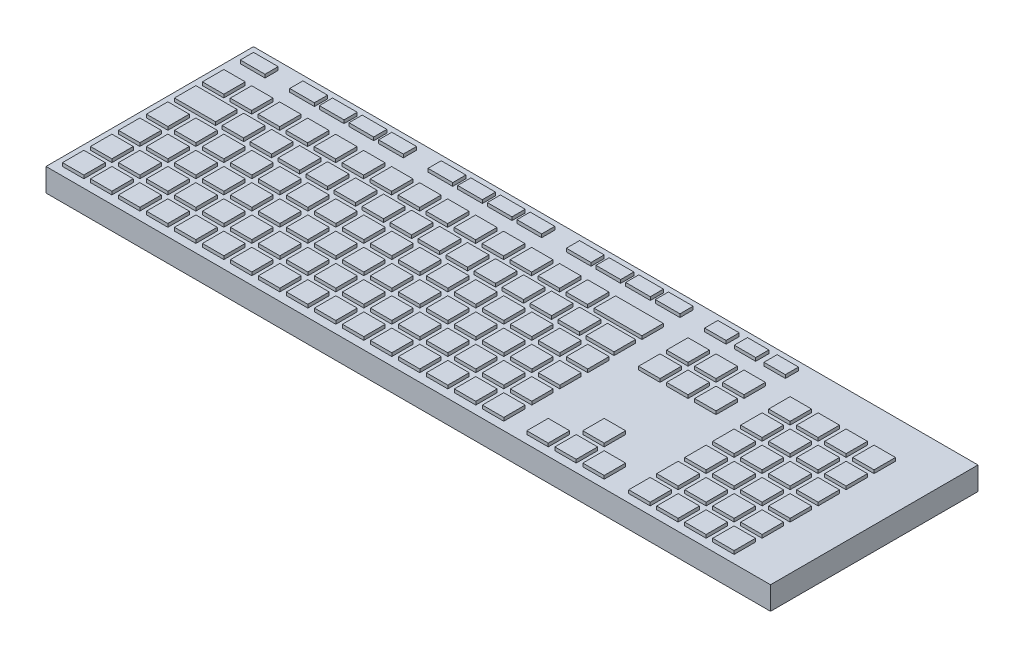
from build123d import *

# Parameters (mm, degrees)
SKETCH1_W            = 440
SKETCH1_H            = 126
BOSS_EXTRUDE1_DEPTH  = 14
SKETCH4_W            = 15
SKETCH4_H            = 8
BOSS_EXTRUDE2_DEPTH  = 2
SKETCH5_W            = 15
SKETCH5_H            = 8
BOSS_EXTRUDE3_DEPTH  = 2
LPATTERN1_COUNT      = 4
LPATTERN1_PITCH      = 18
SKETCH6_W            = 15
SKETCH6_H            = 8
BOSS_EXTRUDE4_DEPTH  = 2
LPATTERN2_COUNT      = 4
LPATTERN2_PITCH      = 18
SKETCH7_W            = 15
SKETCH7_H            = 8
BOSS_EXTRUDE5_DEPTH  = 2
LPATTERN3_COUNT      = 4
LPATTERN3_PITCH      = 18
SKETCH8_W            = 13
SKETCH8_H            = 8
BOSS_EXTRUDE6_DEPTH  = 2
LPATTERN4_COUNT      = 3
LPATTERN4_PITCH      = 18
SKETCH9_W            = 13
SKETCH9_H            = 13
BOSS_EXTRUDE7_DEPTH  = 2
SKETCH10_W           = 13
SKETCH10_H           = 13
BOSS_EXTRUDE8_DEPTH  = 2
LPATTERN5_COUNT      = 13
LPATTERN5_PITCH      = 17
SKETCH11_W           = 29
SKETCH11_H           = 13
BOSS_EXTRUDE9_DEPTH  = 2
SKETCH12_W           = 25
SKETCH12_H           = 13
BOSS_EXTRUDE10_DEPTH = 2
SKETCH13_W           = 13
SKETCH13_H           = 13
BOSS_EXTRUDE11_DEPTH = 2
LPATTERN6_COUNT      = 13
LPATTERN6_PITCH      = 17
SKETCH14_W           = 17
SKETCH14_H           = 13
BOSS_EXTRUDE12_DEPTH = 2
SKETCH15_W           = 13
SKETCH15_H           = 13
BOSS_EXTRUDE13_DEPTH = 2
LPATTERN7_COUNT      = 16
LPATTERN7_PITCH      = 17
LPATTERN7_COUNT_DIR2 = 4
LPATTERN7_PITCH_DIR2 = 17
SKETCH16_W           = 13
SKETCH16_H           = 13
BOSS_EXTRUDE14_DEPTH = 2
LPATTERN8_COUNT      = 3
LPATTERN8_PITCH      = 17
LPATTERN8_COUNT_DIR2 = 2
LPATTERN8_PITCH_DIR2 = 17
SKETCH17_W           = 13
SKETCH17_H           = 13
BOSS_EXTRUDE15_DEPTH = 2
LPATTERN9_COUNT      = 4
LPATTERN9_PITCH      = 17
LPATTERN9_COUNT_DIR2 = 6
LPATTERN9_PITCH_DIR2 = 17
SKETCH18_W           = 13
SKETCH18_H           = 13
BOSS_EXTRUDE16_DEPTH = 2
SKETCH19_W           = 13
SKETCH19_H           = 13
BOSS_EXTRUDE17_DEPTH = 2
LPATTERN10_COUNT     = 3
LPATTERN10_PITCH     = 17


with BuildPart() as part:
    # Sketch1 → Boss-Extrude1 (new body)
    with BuildSketch(Plane(origin=(0, 0, 0), x_dir=(1, 0, 0), z_dir=(0, 1, 0))):
        Rectangle(SKETCH1_W, SKETCH1_H)
    extrude(amount=BOSS_EXTRUDE1_DEPTH)

    # Sketch4 → Boss-Extrude2 (add)
    with BuildSketch(Plane(origin=(0, 14, 0), x_dir=(1, 0, 0), z_dir=(0, 1, 0))):
        with Locations((-207.5, 54)):
            Rectangle(SKETCH4_W, SKETCH4_H)
    extrude(amount=BOSS_EXTRUDE2_DEPTH)

    # Sketch5 → Boss-Extrude3 (add)
    with BuildSketch(Plane(origin=(0, 14, 0), x_dir=(1, 0, 0), z_dir=(0, 1, 0))):
        with Locations((-177.5, 54)):
            Rectangle(SKETCH5_W, SKETCH5_H)
    boss_extrude3 = extrude(amount=BOSS_EXTRUDE3_DEPTH)

    # LPattern1: Boss-Extrude3 ×4
    with Locations(*[(i * LPATTERN1_PITCH, 0, 0) for i in range(1, LPATTERN1_COUNT)]):
        add(boss_extrude3)

    # Sketch6 → Boss-Extrude4 (add)
    with BuildSketch(Plane(origin=(0, 14, 0), x_dir=(1, 0, 0), z_dir=(0, 1, 0))):
        with Locations((-93.5, 54)):
            Rectangle(SKETCH6_W, SKETCH6_H)
    boss_extrude4 = extrude(amount=BOSS_EXTRUDE4_DEPTH)

    # LPattern2: Boss-Extrude4 ×4
    with Locations(*[(i * LPATTERN2_PITCH, 0, 0) for i in range(1, LPATTERN2_COUNT)]):
        add(boss_extrude4)

    # Sketch7 → Boss-Extrude5 (add)
    with BuildSketch(Plane(origin=(0, 14, 0), x_dir=(1, 0, 0), z_dir=(0, 1, 0))):
        with Locations((-9.5, 54)):
            Rectangle(SKETCH7_W, SKETCH7_H)
    boss_extrude5 = extrude(amount=BOSS_EXTRUDE5_DEPTH)

    # LPattern3: Boss-Extrude5 ×4
    with Locations(*[(i * LPATTERN3_PITCH, 0, 0) for i in range(1, LPATTERN3_COUNT)]):
        add(boss_extrude5)

    # Sketch8 → Boss-Extrude6 (add)
    with BuildSketch(Plane(origin=(0, 14, 0), x_dir=(1, 0, 0), z_dir=(0, 1, 0))):
        with Locations((73.5, 54)):
            Rectangle(SKETCH8_W, SKETCH8_H)
    boss_extrude6 = extrude(amount=BOSS_EXTRUDE6_DEPTH)

    # LPattern4: Boss-Extrude6 ×3
    with Locations(*[(i * LPATTERN4_PITCH, 0, 0) for i in range(1, LPATTERN4_COUNT)]):
        add(boss_extrude6)

    # Sketch9 → Boss-Extrude7 (add)
    with BuildSketch(Plane(origin=(0, 14, 0), x_dir=(1, 0, 0), z_dir=(0, 1, 0))):
        with Locations((-208.5, 33.5)):
            Rectangle(SKETCH9_W, SKETCH9_H)
    extrude(amount=BOSS_EXTRUDE7_DEPTH)

    # Sketch10 → Boss-Extrude8 (add)
    with BuildSketch(Plane(origin=(0, 14, 0), x_dir=(1, 0, 0), z_dir=(0, 1, 0))):
        with Locations((-191.5, 33.382625631)):
            Rectangle(SKETCH10_W, SKETCH10_H)
    boss_extrude8 = extrude(amount=BOSS_EXTRUDE8_DEPTH)

    # LPattern5: Boss-Extrude8 ×13
    with Locations(*[(i * LPATTERN5_PITCH, 0, 0) for i in range(1, LPATTERN5_COUNT)]):
        add(boss_extrude8)

    # Sketch11 → Boss-Extrude9 (add)
    with BuildSketch(Plane(origin=(0, 14, 0), x_dir=(1, 0, 0), z_dir=(0, 1, 0))):
        with Locations((37.5, 33.382625631)):
            Rectangle(SKETCH11_W, SKETCH11_H)
    extrude(amount=BOSS_EXTRUDE9_DEPTH)

    # Sketch12 → Boss-Extrude10 (add)
    with BuildSketch(Plane(origin=(0, 14, 0), x_dir=(1, 0, 0), z_dir=(0, 1, 0))):
        with Locations((-202.5, 16.5)):
            Rectangle(SKETCH12_W, SKETCH12_H)
    extrude(amount=BOSS_EXTRUDE10_DEPTH)

    # Sketch13 → Boss-Extrude11 (add)
    with BuildSketch(Plane(origin=(0, 14, 0), x_dir=(1, 0, 0), z_dir=(0, 1, 0))):
        with Locations((-179.5, 16.5)):
            Rectangle(SKETCH13_W, SKETCH13_H)
    boss_extrude11 = extrude(amount=BOSS_EXTRUDE11_DEPTH)

    # LPattern6: Boss-Extrude11 ×13
    with Locations(*[(i * LPATTERN6_PITCH, 0, 0) for i in range(1, LPATTERN6_COUNT)]):
        add(boss_extrude11)

    # Sketch14 → Boss-Extrude12 (add)
    with BuildSketch(Plane(origin=(0, 14, 0), x_dir=(1, 0, 0), z_dir=(0, 1, 0))):
        with Locations((43.5, 16.5)):
            Rectangle(SKETCH14_W, SKETCH14_H)
    extrude(amount=BOSS_EXTRUDE12_DEPTH)

    # Sketch15 → Boss-Extrude13 (add)
    with BuildSketch(Plane(origin=(0, 14, 0), x_dir=(1, 0, 0), z_dir=(0, 1, 0))):
        with Locations((-208.5, -0.5)):
            Rectangle(SKETCH15_W, SKETCH15_H)
    boss_extrude13 = extrude(amount=BOSS_EXTRUDE13_DEPTH)

    # LPattern7: Boss-Extrude13 16 × 4
    with Locations(*[(i * LPATTERN7_PITCH, 0, j * LPATTERN7_PITCH_DIR2) for i in range(LPATTERN7_COUNT) for j in range(LPATTERN7_COUNT_DIR2) if (i, j) != (0, 0)]):
        add(boss_extrude13)

    # Sketch16 → Boss-Extrude14 (add)
    with BuildSketch(Plane(origin=(0, 14, 0), x_dir=(1, 0, 0), z_dir=(0, 1, 0))):
        with Locations((73.5, 33.382625631)):
            Rectangle(SKETCH16_W, SKETCH16_H)
    boss_extrude14 = extrude(amount=BOSS_EXTRUDE14_DEPTH)

    # LPattern8: Boss-Extrude14 3 × 2
    with Locations(*[(i * LPATTERN8_PITCH, 0, j * LPATTERN8_PITCH_DIR2) for i in range(LPATTERN8_COUNT) for j in range(LPATTERN8_COUNT_DIR2) if (i, j) != (0, 0)]):
        add(boss_extrude14)

    # Sketch17 → Boss-Extrude15 (add)
    with BuildSketch(Plane(origin=(0, 14, 0), x_dir=(1, 0, 0), z_dir=(0, 1, 0))):
        with Locations((135.5, 33.382625631)):
            Rectangle(SKETCH17_W, SKETCH17_H)
    boss_extrude15 = extrude(amount=BOSS_EXTRUDE15_DEPTH)

    # LPattern9: Boss-Extrude15 4 × 6
    with Locations(*[(i * LPATTERN9_PITCH, 0, j * LPATTERN9_PITCH_DIR2) for i in range(LPATTERN9_COUNT) for j in range(LPATTERN9_COUNT_DIR2) if (i, j) != (0, 0)]):
        add(boss_extrude15)

    # Sketch18 → Boss-Extrude16 (add)
    with BuildSketch(Plane(origin=(0, 14, 0), x_dir=(1, 0, 0), z_dir=(0, 1, 0))):
        with Locations((90.5, -34.5)):
            Rectangle(SKETCH18_W, SKETCH18_H)
    extrude(amount=BOSS_EXTRUDE16_DEPTH)

    # Sketch19 → Boss-Extrude17 (add)
    with BuildSketch(Plane(origin=(0, 14, 0), x_dir=(1, 0, 0), z_dir=(0, 1, 0))):
        with Locations((73.5, -51.5)):
            Rectangle(SKETCH19_W, SKETCH19_H)
    boss_extrude17 = extrude(amount=BOSS_EXTRUDE17_DEPTH)

    # LPattern10: Boss-Extrude17 ×3
    with Locations(*[(i * LPATTERN10_PITCH, 0, 0) for i in range(1, LPATTERN10_COUNT)]):
        add(boss_extrude17)


solid = part.part
